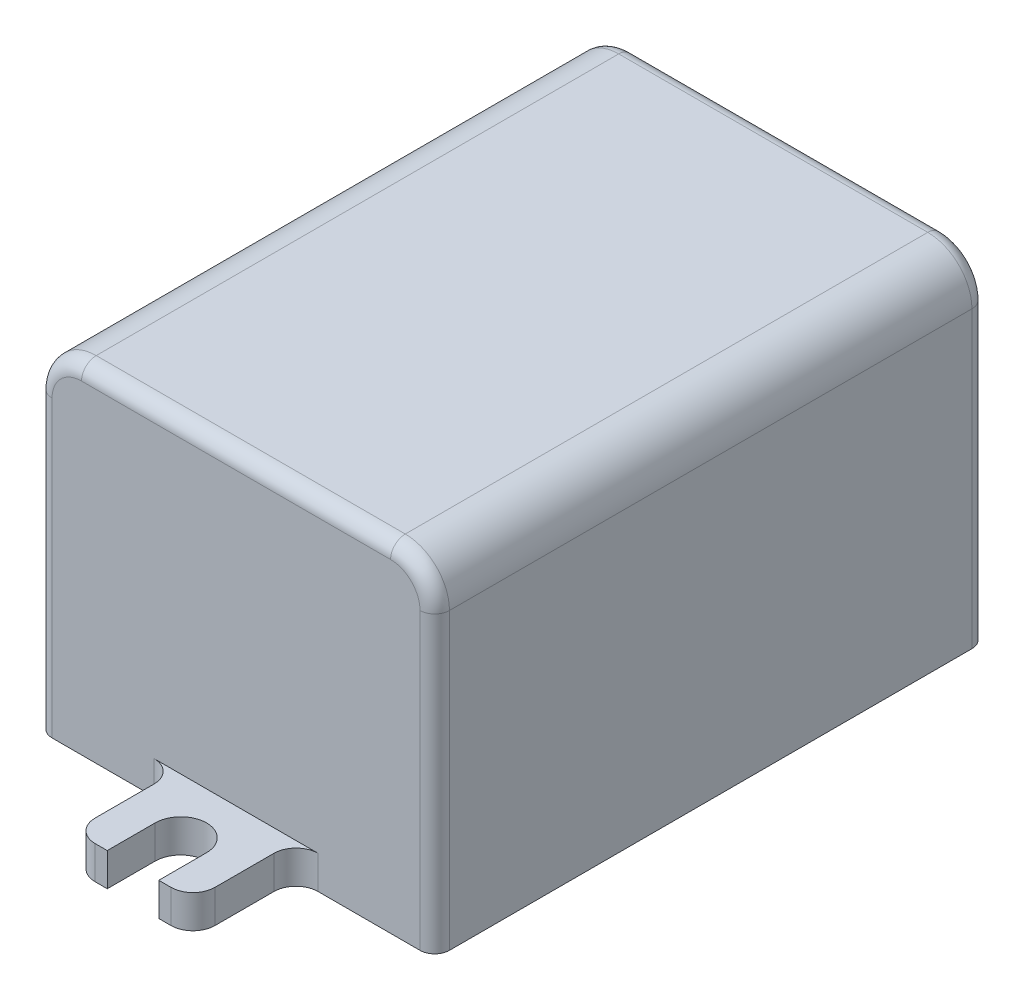
from build123d import *

# Parameters (mm, degrees)
SKETCH1_W           = 27
SKETCH1_H           = 37.5
BOSS_EXTRUDE1_DEPTH = 23
BOSS_EXTRUDE2_DEPTH = 2.25
FILLET1_R           = 3
FILLET2_R           = 1


with BuildPart() as part:
    # Sketch1 → Boss-Extrude1 (new body)
    with BuildSketch(Plane(origin=(0, 0, 0), x_dir=(1, 0, 0), z_dir=(0, 1, 0))):
        Rectangle(SKETCH1_W, SKETCH1_H)
    extrude(amount=BOSS_EXTRUDE1_DEPTH)

    # Sketch2 → Boss-Extrude2 (add)
    with BuildSketch(Plane(origin=(0, 0, 0), x_dir=(1, 0, 0), z_dir=(0, 1, 0))):
        with BuildLine():
            Line((-1.75, -22.5), (-1.75, -25.75))
            Line((-1.75, -25.75), (-2.575, -25.75))
            ThreePointArc((-2.575, -25.75), (-3.635660172, -25.310660172), (-4.075, -24.25))
            Line((-4.075, -24.25), (-4.075, -20.25))
            ThreePointArc((-4.075, -20.25), (-4.514339828, -19.189339828), (-5.575, -18.75))
            Line((-5.575, -18.75), (5.575, -18.75))
            ThreePointArc((5.575, -18.75), (4.514339828, -19.189339828), (4.075, -20.25))
            Line((4.075, -20.25), (4.075, -24.25))
            ThreePointArc((4.075, -24.25), (3.635660172, -25.310660172), (2.575, -25.75))
            Line((2.575, -25.75), (1.75, -25.75))
            Line((1.75, -25.75), (1.75, -22.5))
            ThreePointArc((1.75, -22.5), (0, -20.75), (-1.75, -22.5))
        make_face()
        with BuildLine():
            Line((1.75, 22.5), (1.75, 25.75))
            Line((1.75, 25.75), (2.575, 25.75))
            ThreePointArc((2.575, 25.75), (3.635660172, 25.310660172), (4.075, 24.25))
            Line((4.075, 24.25), (4.075, 20.25))
            ThreePointArc((4.075, 20.25), (4.514339828, 19.189339828), (5.575, 18.75))
            Line((5.575, 18.75), (-5.575, 18.75))
            ThreePointArc((-5.575, 18.75), (-4.514339828, 19.189339828), (-4.075, 20.25))
            Line((-4.075, 20.25), (-4.075, 24.25))
            ThreePointArc((-4.075, 24.25), (-3.635660172, 25.310660172), (-2.575, 25.75))
            Line((-2.575, 25.75), (-1.75, 25.75))
            Line((-1.75, 25.75), (-1.75, 22.5))
            ThreePointArc((-1.75, 22.5), (0, 20.75), (1.75, 22.5))
        make_face()
    extrude(amount=BOSS_EXTRUDE2_DEPTH)

    # Fillet1
    fillet1_edges = [part.edges().sort_by_distance(p)[0] for p in [
        (13.5, 23, 0),
        (-13.5, 23, 0),
    ]]
    fillet(fillet1_edges, radius=FILLET1_R)

    # Fillet2
    fillet2_edges = [part.edges().sort_by_distance(p)[0] for p in [
        (0, 23, 18.75),
        (0, 23, -18.75),
        (-13.5, 10, -18.75),
        (13.5, 10, -18.75),
        (-12.621320344, 22.121320344, -18.75),
        (12.621320344, 22.121320344, -18.75),
        (13.5, 10, 18.75),
        (-13.5, 10, 18.75),
        (-12.621320344, 22.121320344, 18.75),
        (12.621320344, 22.121320344, 18.75),
    ]]
    fillet(fillet2_edges, radius=FILLET2_R)


solid = part.part
